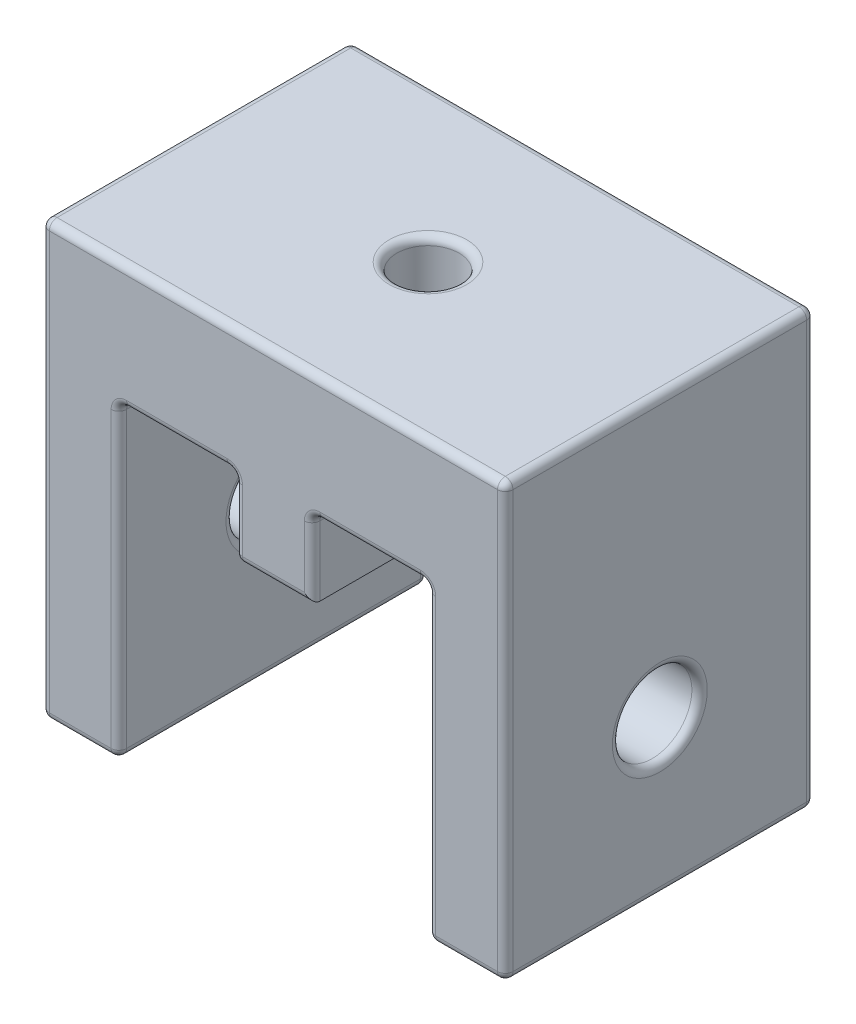
from build123d import *

# Parameters (mm, degrees)
BOSS_EXTRUDE1_DEPTH              = 25.4
SKETCH2_W                        = 6.35
SKETCH2_H                        = 7.62
BOSS_EXTRUDE2_DEPTH              = 6.35
F_1_4_20_TAPPED_HOLE1_D          = 5.1054
F_97_0_0059_DIAMETER_HOLE1_D     = 6.5278
F_97_0_0059_DIAMETER_HOLE1_DEPTH = 6.35
F_97_0_0059_DIAMETER_HOLE2_D     = 6.5278
FILLET2_R                        = 0.635


with BuildPart() as part:
    # Sketch1 → Boss-Extrude1 (new body)
    with BuildSketch(Plane.XY):
        Polygon((0, 0), (6.35, 0), (6.35, 25.4), (31.75, 25.4), (31.75, 0), (38.1, 0), (38.1, 35.56), (0, 35.56), align=None)
    extrude(amount=BOSS_EXTRUDE1_DEPTH)

    # Sketch2 → Boss-Extrude2 (add)
    with BuildSketch(Plane.XZ.offset(-25.4)):
        with Locations((19.05, 3.81)):
            Rectangle(SKETCH2_W, SKETCH2_H)
    boss_extrude2 = extrude(amount=BOSS_EXTRUDE2_DEPTH)

    # Mirror1: Boss-Extrude2 across plane
    add(boss_extrude2.mirror(Plane.XY.offset(12.7)))

    # 1/4-20 Tapped Hole1 (through all)
    with Locations(Plane(origin=(0, 35.56, 0), x_dir=(-1, 0, 0), z_dir=(0, 1, 0))):
        with Locations((-19.05, 12.7)):
            Hole(F_1_4_20_TAPPED_HOLE1_D / 2)

    # #97 (0.0059) Diameter Hole1
    with Locations(Plane(origin=(6.35, 0, 0), x_dir=(0, 0, -1), z_dir=(1, 0, 0))):
        with Locations((-12.7, 12.7)):
            Hole(F_97_0_0059_DIAMETER_HOLE1_D / 2, depth=F_97_0_0059_DIAMETER_HOLE1_DEPTH)

    # #97 (0.0059) Diameter Hole2 (through all)
    with Locations(Plane.ZY.offset(-31.75)):
        with Locations((12.7, 12.7)):
            Hole(F_97_0_0059_DIAMETER_HOLE2_D / 2)

    # Fillet2
    fillet2_edges = [part.edges().sort_by_distance(p)[0] for p in [
        (31.75, 0, 12.7),
        (31.75, 12.7, 15.9639),
        (6.35, 0, 12.7),
        (6.35, 12.7, 9.4361),
        (22.225, 25.4, 21.59),
        (31.75, 25.4, 12.7),
        (22.225, 25.4, 3.81),
        (19.05, 25.4, 7.62),
        (15.875, 25.4, 3.81),
        (6.35, 25.4, 12.7),
        (15.875, 25.4, 21.59),
        (19.05, 25.4, 17.78),
        (16.4973, 25.4, 12.7),
        (34.925, 0, 25.4),
        (31.75, 12.7, 25.4),
        (26.9875, 25.4, 25.4),
        (22.225, 22.225, 25.4),
        (22.225, 22.225, 17.78),
        (19.05, 19.05, 17.78),
        (19.05, 19.05, 25.4),
        (15.875, 22.225, 17.78),
        (15.875, 22.225, 25.4),
        (11.1125, 25.4, 25.4),
        (6.35, 12.7, 25.4),
        (3.175, 0, 25.4),
        (3.175, 0, 0),
        (6.35, 12.7, 0),
        (11.1125, 25.4, 0),
        (15.875, 22.225, 0),
        (19.05, 19.05, 0),
        (22.225, 22.225, 0),
        (26.9875, 25.4, 0),
        (31.75, 12.7, 0),
        (34.925, 0, 0),
        (0, 17.78, 25.4),
        (0, 0, 12.7),
        (0, 17.78, 0),
        (0, 12.7, 9.4361),
        (38.1, 0, 12.7),
        (38.1, 17.78, 25.4),
        (38.1, 17.78, 0),
        (38.1, 12.7, 15.9639),
        (38.1, 35.56, 12.7),
        (19.05, 35.56, 25.4),
        (0, 35.56, 12.7),
        (19.05, 35.56, 0),
        (16.4973, 35.56, 12.7),
        (22.225, 22.225, 7.62),
        (15.875, 22.225, 7.62),
        (15.875, 19.05, 3.81),
        (19.05, 19.05, 7.62),
        (22.225, 19.05, 3.81),
        (15.875, 19.05, 21.59),
    ]]
    fillet(fillet2_edges, radius=FILLET2_R)


solid = part.part
